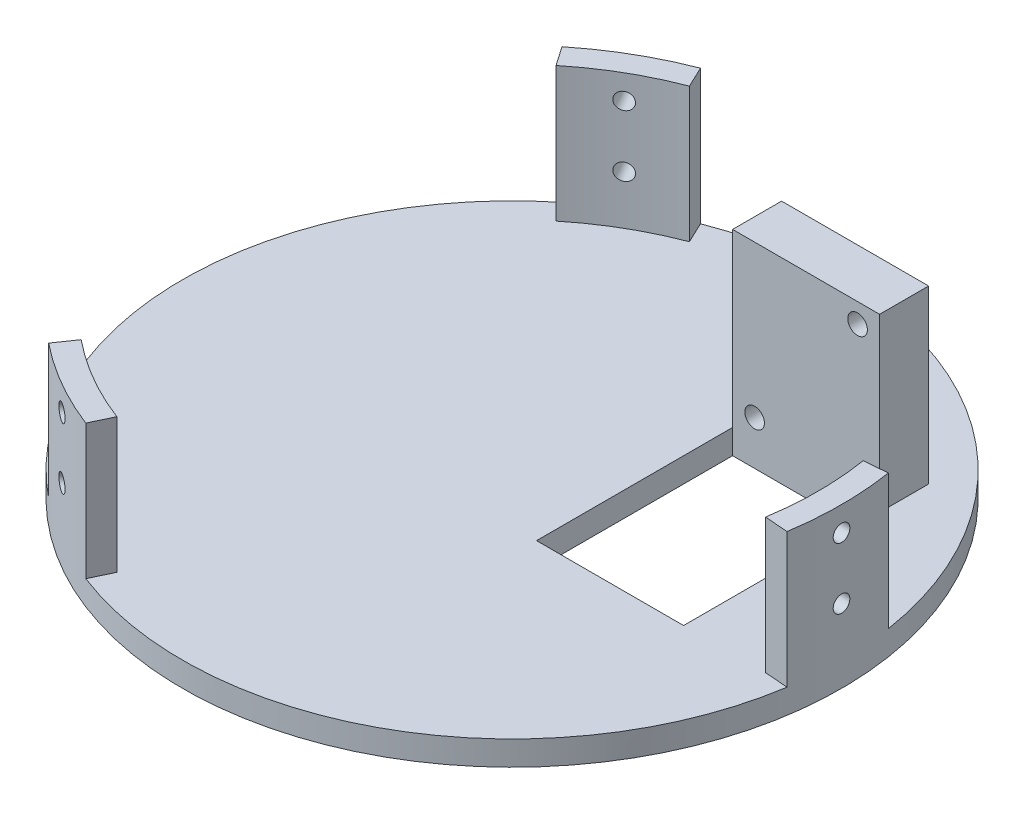
from build123d import *

# Parameters (mm, degrees)
SKETCH1_W           = 127.635
SKETCH1_H           = 127.635
MAIN_PLATE_DEPTH    = 6.35
SKETCH9_R           = 85.725
BOSS_EXTRUDE1_DEPTH = 6.35
SKETCH10_R          = 95.25
SKETCH10_R_2        = 85.4075
CUT_EXTRUDE1_DEPTH  = 167.64
SKETCH18_R          = 85.4075
SKETCH18_R_2        = 79.375
BOSS_EXTRUDE2_DEPTH = 38.1
SKETCH15_R          = 2.159
CUT_EXTRUDE3_DEPTH  = 88.9
CIRPATTERN1_COUNT   = 3
SKETCH23_R          = 79.375
CUT_EXTRUDE6_DEPTH  = 111.600000066
SKETCH24_W          = 38.1
SKETCH24_H          = 50.8
CUT_EXTRUDE7_DEPTH  = 7.35
SKETCH25_W          = 38.1
SKETCH25_H          = 12.7
BOSS_EXTRUDE3_DEPTH = 44.45
SKETCH26_R          = 2.54
CUT_EXTRUDE8_DEPTH  = 44.45


with BuildPart() as part:
    # Sketch1 → Main Plate (new body)
    with BuildSketch(Plane(origin=(0, 0, 0), x_dir=(1, 0, 0), z_dir=(0, 1, 0))):
        with Locations((63.8175, 63.8175)):
            Rectangle(SKETCH1_W, SKETCH1_H)
    extrude(amount=MAIN_PLATE_DEPTH)

    # Sketch9 → Boss-Extrude1 (add)
    with BuildSketch(Plane(origin=(0, 6.35, 0), x_dir=(1, 0, 0), z_dir=(0, 1, 0))):
        with Locations((63.8175, 63.8175)):
            Circle(SKETCH9_R)
    extrude(amount=-BOSS_EXTRUDE1_DEPTH)

    # Sketch10 → Cut-Extrude1 (cut)
    with BuildSketch(Plane(origin=(0, 6.35, 0), x_dir=(1, 0, 0), z_dir=(0, 1, 0))):
        with Locations((63.8175, 63.8175)):
            Circle(SKETCH10_R)
        with Locations((63.8175, 63.8175)):
            Circle(SKETCH10_R_2, mode=Mode.SUBTRACT)
    extrude(amount=-CUT_EXTRUDE1_DEPTH, mode=Mode.SUBTRACT)

    # Sketch18 → Boss-Extrude2 (add)
    with BuildSketch(Plane(origin=(0, 3.175, 0), x_dir=(1, 0, 0), z_dir=(0, 1, 0))):
        with Locations((63.8175, 63.8175)):
            Circle(SKETCH18_R)
        with Locations((63.8175, 63.8175)):
            Circle(SKETCH18_R_2, mode=Mode.SUBTRACT)
    extrude(amount=BOSS_EXTRUDE2_DEPTH)

    # Sketch15 → Cut-Extrude3 (cut)
    with BuildSketch(Plane(origin=(166.221610148, -6.35, 178.614251028), x_dir=(-0.866025404, 0, -0.5), z_dir=(0.5, 0, -0.866025404))):
        with Locations((209.900436354, 25.4)):
            Circle(SKETCH15_R)
        with Locations((209.900436354, 41.275)):
            Circle(SKETCH15_R)
    cut_extrude3 = extrude(amount=CUT_EXTRUDE3_DEPTH, mode=Mode.SUBTRACT)

    # CirPattern1: Cut-Extrude3 ×3 about axis
    cirpattern1_axis = Axis((63.8175, -161.29, -63.8175), (0, 1, 0))
    for i in range(1, CIRPATTERN1_COUNT):
        add(cut_extrude3.rotate(cirpattern1_axis, i * 360 / CIRPATTERN1_COUNT), mode=Mode.SUBTRACT)

    # Sketch23 → Cut-Extrude6 (cut)
    with BuildSketch(Plane(origin=(0, 6.35, 0), x_dir=(1, 0, 0), z_dir=(0, 1, 0))):
        with Locations((63.8175, 63.8175)):
            Circle(SKETCH23_R)
        with BuildLine():
            Line((13.678739997, 125.352005526), (7.552270878, 134.237860218))
            Line((7.552270878, 134.237860218), (-19.267108419, 125.320629884))
            Line((-19.267108419, 125.320629884), (-48.79695837, 60.397770071))
            Line((-48.79695837, 60.397770071), (-9.884344094, 7.052469015))
            Line((-9.884344094, 7.052469015), (6.959175986, -7.46308736))
            Line((6.959175986, -7.46308736), (13.678739997, 2.282994474))
            ThreePointArc((13.678739997, 2.282994474), (-15.5575, 63.8175), (13.678739997, 125.352005526))
        make_face()
        with BuildLine():
            Line((142.177324996, 76.471687114), (152.935935453, 77.334437661))
            Line((152.935935453, 77.334437661), (158.623077101, 105.019316613))
            Line((158.623077101, 105.019316613), (117.163156193, 163.054346747))
            Line((117.163156193, 163.054346747), (51.508463168, 156.027684783))
            Line((51.508463168, 156.027684783), (30.515862556, 148.698546693))
            Line((30.515862556, 148.698546693), (35.596435007, 138.00619264))
            ThreePointArc((35.596435007, 138.00619264), (103.505, 132.558266425), (142.177324996, 76.471687114))
        make_face()
        with BuildLine():
            Line((35.596435007, -10.37119264), (30.964293669, -20.119797879))
            Line((30.964293669, -20.119797879), (52.096531318, -38.887446496))
            Line((52.096531318, -38.887446496), (123.086302178, -31.999616818))
            Line((123.086302178, -31.999616818), (149.828380926, 28.372346201))
            Line((149.828380926, 28.372346201), (153.977461458, 50.217040667))
            Line((153.977461458, 50.217040667), (142.177324996, 51.163312886))
            ThreePointArc((142.177324996, 51.163312886), (103.505, -4.923266425), (35.596435007, -10.37119264))
        make_face()
    extrude(amount=CUT_EXTRUDE6_DEPTH, mode=Mode.SUBTRACT)

    # Sketch24 → Cut-Extrude7 (cut, through all)
    with BuildSketch(Plane(origin=(0, 6.35, 0), x_dir=(1, 0, 0), z_dir=(0, 1, 0))):
        with Locations((101.9175, 76.5175)):
            Rectangle(SKETCH24_W, SKETCH24_H)
    extrude(amount=-CUT_EXTRUDE7_DEPTH, mode=Mode.SUBTRACT)

    # Sketch25 → Boss-Extrude3 (add)
    with BuildSketch(Plane(origin=(0, 6.35, 0), x_dir=(1, 0, 0), z_dir=(0, 1, 0))):
        with Locations((101.9175, 108.2675)):
            Rectangle(SKETCH25_W, SKETCH25_H)
    extrude(amount=BOSS_EXTRUDE3_DEPTH)

    # Sketch26 → Cut-Extrude8 (cut)
    with BuildSketch(Plane.XY.offset(-101.9175)):
        with Locations((115.2525, 45.72)):
            Circle(SKETCH26_R)
        with Locations((88.5825, 11.43)):
            Circle(SKETCH26_R)
    extrude(amount=-CUT_EXTRUDE8_DEPTH, mode=Mode.SUBTRACT)


solid = part.part
